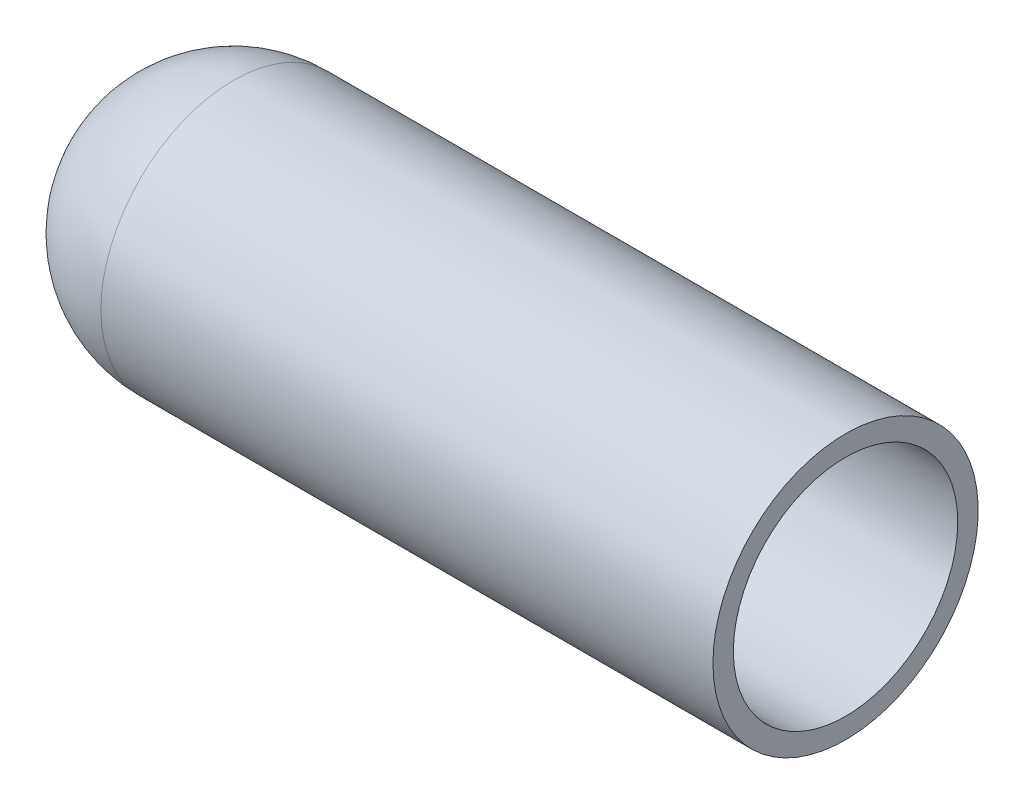
from build123d import *

# Parameters (mm, degrees)
SHELL2_T = -0.508


with BuildPart() as part:
    # Sketch1 → Revolve2 (revolve)
    with BuildSketch(Plane.XY):
        with BuildLine():
            Line((0, 3.302), (15.24, 3.302))
            Line((15.24, 3.302), (15.24, 0))
            Line((15.24, 0), (-3.302, 0))
            ThreePointArc((-3.302, 0), (-2.334866591, 2.334866591), (0, 3.302))
        make_face()
    revolve(axis=Axis((-3.302, 0, 0), (1, 0, 0)))

    # Shell2
    shell2_openings = [part.faces().sort_by_distance(p)[0] for p in [
        (15.24, 0, 0),
    ]]
    offset(amount=SHELL2_T, openings=shell2_openings, kind=Kind.INTERSECTION)


solid = part.part
